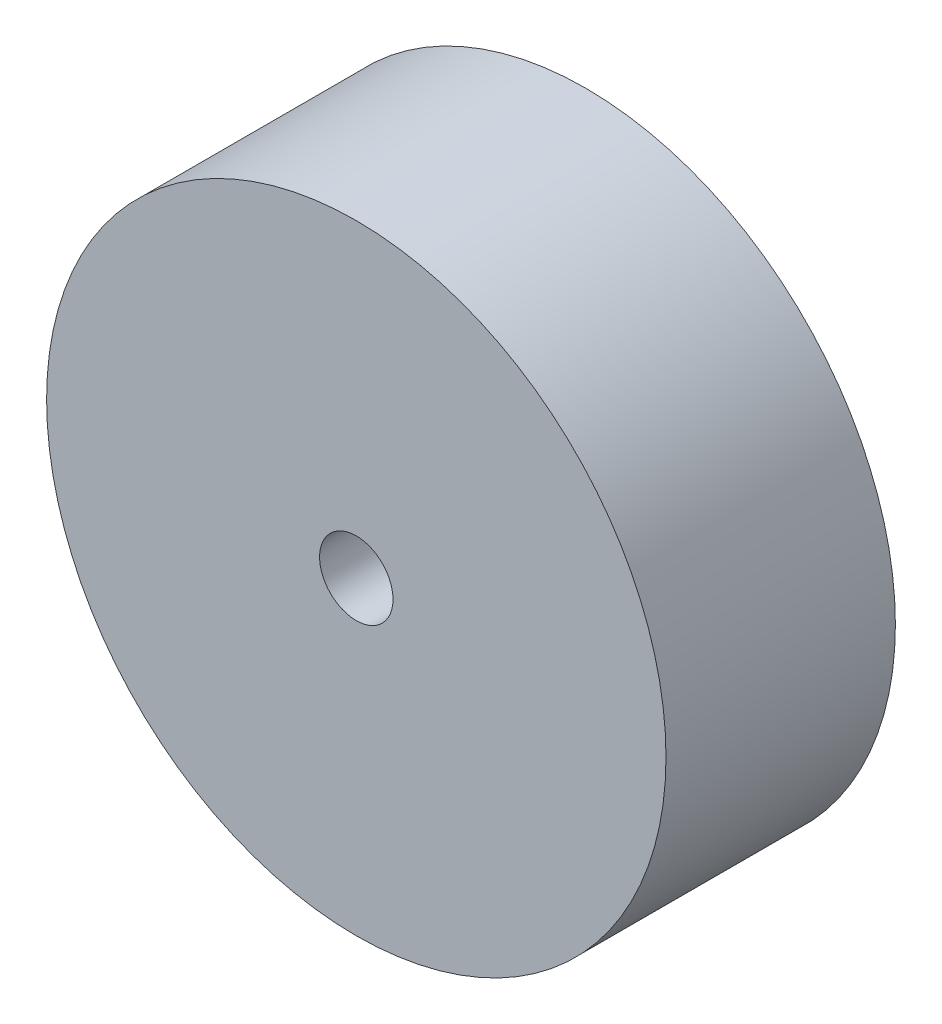
from build123d import *

# Parameters (mm, degrees)
SKETCH1_R           = 67.5
SKETCH1_R_2         = 8
BOSS_EXTRUDE1_DEPTH = 50


with BuildPart() as part:
    # Sketch1 → Boss-Extrude1 (new body)
    with BuildSketch(Plane.XY):
        Circle(SKETCH1_R)
        Circle(SKETCH1_R_2, mode=Mode.SUBTRACT)
    extrude(amount=BOSS_EXTRUDE1_DEPTH)


solid = part.part
